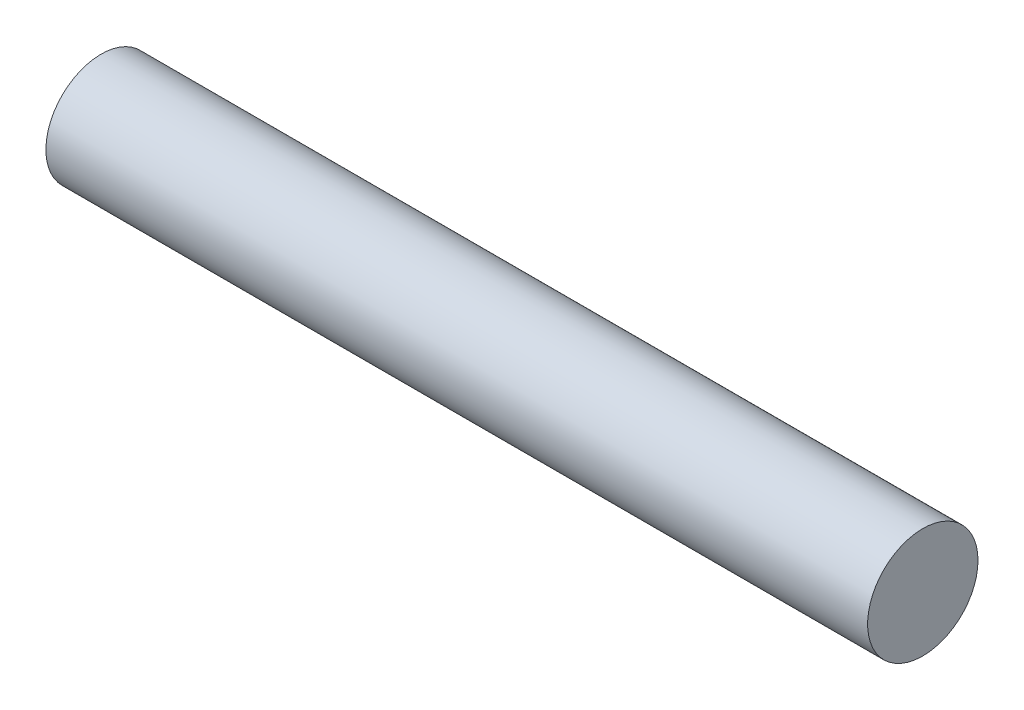
from build123d import *

# Parameters (mm, degrees)
SKETCH1_R                = 6.35
BOSS_EXTRUDE1_DEPTH      = 45.6875
BOSS_EXTRUDE1_DEPTH_BACK = 45.6875
SKETCH3_R                = 6.35
BOSS_EXTRUDE2_DEPTH      = 3.175


with BuildPart() as part:
    # Sketch1 → Boss-Extrude1 (new body, two sides)
    with BuildSketch(Plane(origin=(0, 0, 0), x_dir=(0, 0, -1), z_dir=(1, 0, 0))) as boss_extrude1_sk:
        Circle(SKETCH1_R)
    extrude(amount=BOSS_EXTRUDE1_DEPTH)
    extrude(boss_extrude1_sk.sketch, amount=-BOSS_EXTRUDE1_DEPTH_BACK)

    # Sketch3 → Boss-Extrude2 (add)
    with BuildSketch(Plane(origin=(45.6875, 0, 0), x_dir=(0, 0, -1), z_dir=(1, 0, 0))):
        Circle(SKETCH3_R)
    extrude(amount=BOSS_EXTRUDE2_DEPTH)


solid = part.part
